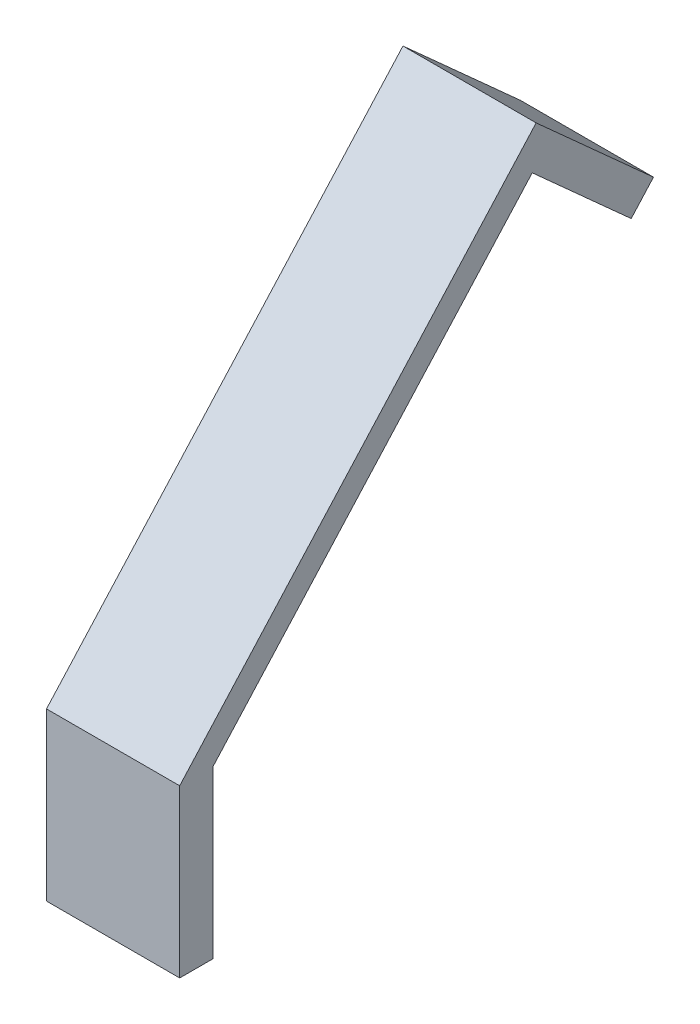
from build123d import *

# Parameters (mm, degrees)
SKETCH1_W           = 12.7
SKETCH1_H           = 63.5
BOSS_EXTRUDE1_DEPTH = 50.8


with BuildPart() as part:
    # Sketch1 → Boss-Extrude1 (new body)
    with BuildSketch(Plane(origin=(0, 0, 0), x_dir=(0, 0, -1), z_dir=(1, 0, 0))):
        Polygon((134.483136253, 198.753875218), (12.7, 63.5), (0, 63.5), (135.967339212, 214.507028537), (180.732852088, 174.199979698), (172.234893387, 164.762040415), align=None)
        with Locations((6.35, 31.75)):
            Rectangle(SKETCH1_W, SKETCH1_H)
    extrude(amount=BOSS_EXTRUDE1_DEPTH)


solid = part.part
